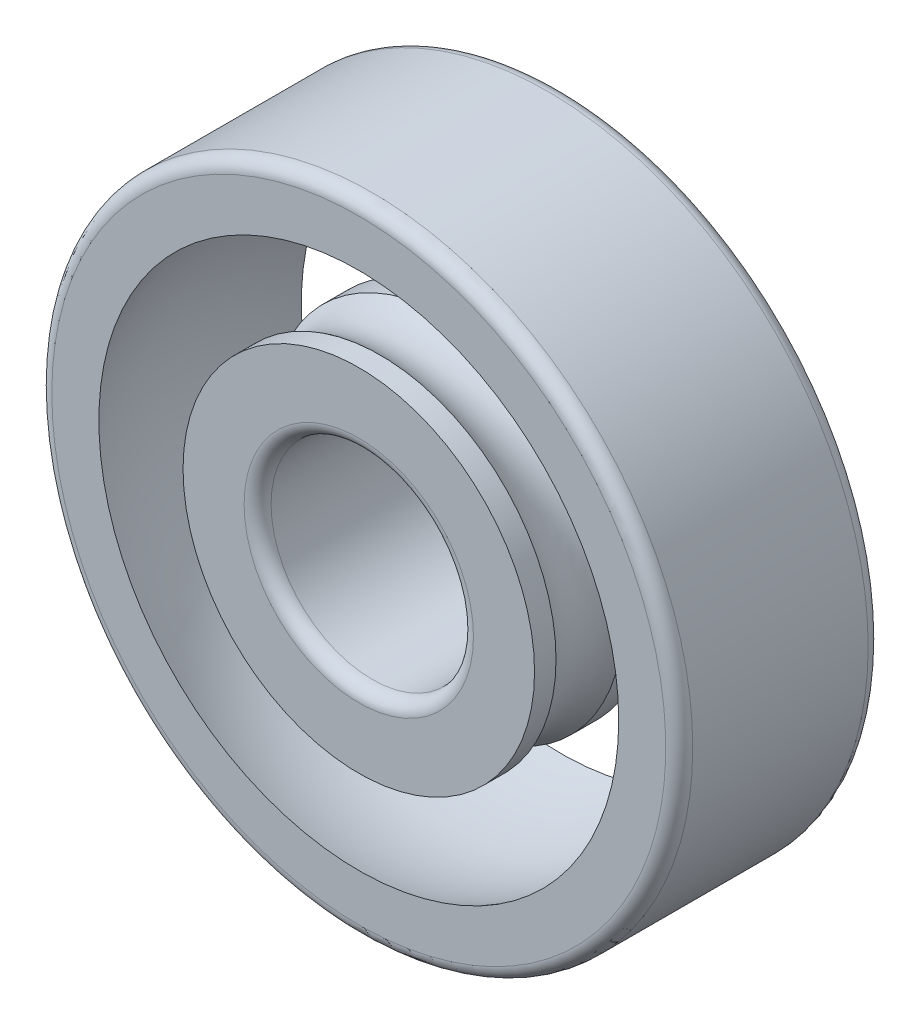
from build123d import *

# Parameters (mm, degrees)
FILLET_1_R = 0.4
FILLET_2_R = 0.4


with BuildPart() as part:
    # Эскиз1 → Повернуть1 (revolve)
    with BuildSketch(Plane(origin=(0, 0, 0), x_dir=(0, 0, -1), z_dir=(1, 0, 0))):
        with BuildLine():
            Line((0, 5.21), (0.636807205, 5.21))
            ThreePointArc((0.636807205, 5.21), (1.625, 4.875), (2.613192795, 5.21))
            Line((2.613192795, 5.21), (3.386807205, 5.21))
            ThreePointArc((3.386807205, 5.21), (4.375, 4.875), (5.363192795, 5.21))
            Line((5.363192795, 5.21), (6, 5.21))
            Line((6, 5.21), (6, 3))
            Line((6, 3), (0, 3))
            Line((0, 3), (0, 5.21))
        make_face()
        with BuildLine():
            Line((0, 9.5), (6, 9.5))
            Line((6, 9.5), (6, 7.705435334))
            ThreePointArc((6, 7.705435334), (3, 8.268841133), (0, 7.705435334))
            Line((0, 7.705435334), (0, 9.5))
        make_face()
    revolve(axis=Axis((0, 0, 0), (0, 0, -1)))

    # Скругление1
    fillet_1_edges = [part.edges().sort_by_distance(p)[0] for p in [
        (0, -3, -6),
        (0, -3, 0),
    ]]
    fillet(fillet_1_edges, radius=FILLET_1_R)

    # Скругление2
    fillet_2_edges = [part.edges().sort_by_distance(p)[0] for p in [
        (0, -9.5, 0),
        (0, -9.5, -6),
    ]]
    fillet(fillet_2_edges, radius=FILLET_2_R)


solid = part.part
